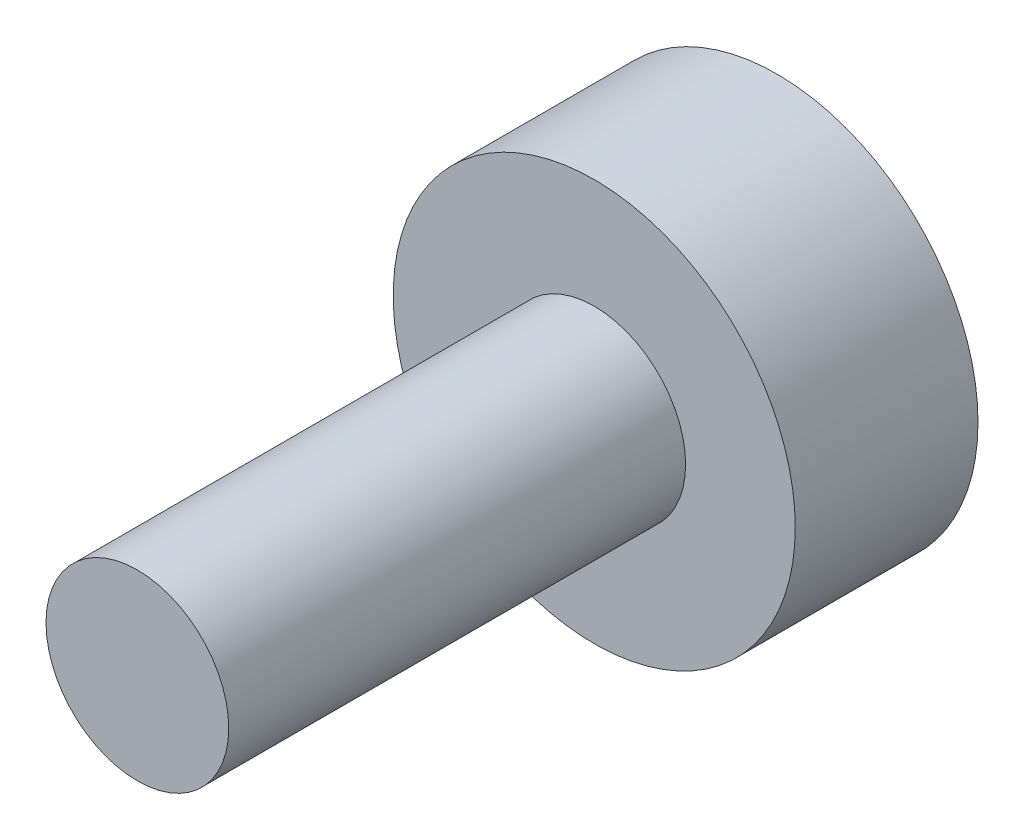
from build123d import *

# Parameters (mm, degrees)
SKETCH1_R           = 11
BOSS_EXTRUDE1_DEPTH = 10
SKETCH2_R           = 5
BOSS_EXTRUDE2_DEPTH = 25


with BuildPart() as part:
    # Sketch1 → Boss-Extrude1 (new body)
    with BuildSketch(Plane.XY):
        Circle(SKETCH1_R)
    extrude(amount=BOSS_EXTRUDE1_DEPTH)

    # Sketch2 → Boss-Extrude2 (add)
    with BuildSketch(Plane.XY.offset(10)):
        Circle(SKETCH2_R)
    extrude(amount=BOSS_EXTRUDE2_DEPTH)


solid = part.part
